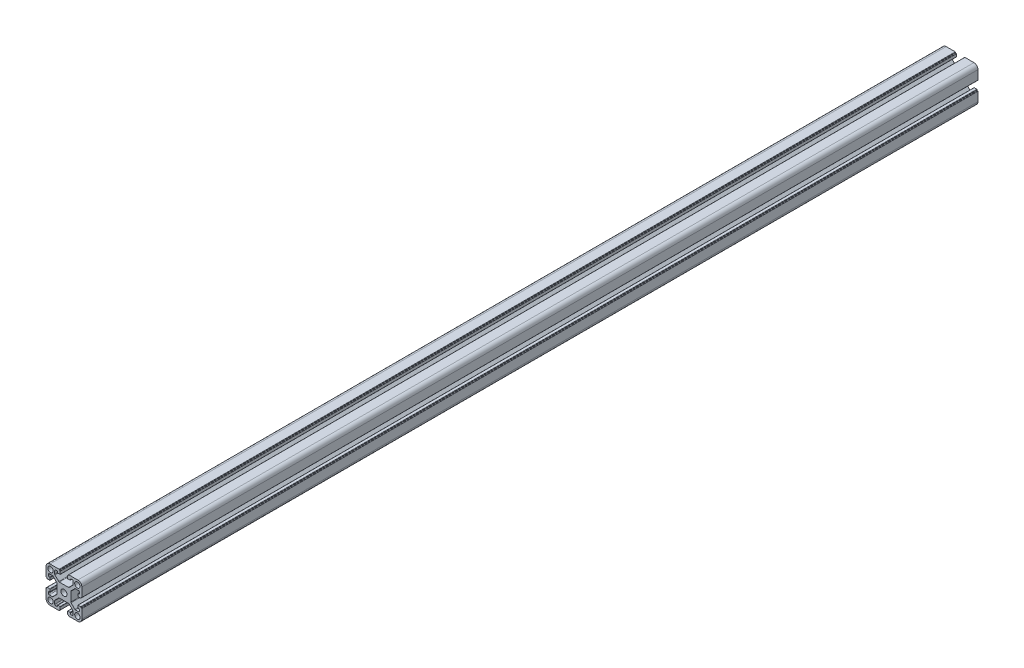
from build123d import *

# Parameters (mm, degrees)
SKETCH_1_R      = 3
SKETCH_1_R_2    = 3.4
EXTRUDE_1_DEPTH = 1000


with BuildPart() as part:
    # Эскиз1 → Бобышка-Вытянуть1 (new body)
    with BuildSketch(Plane.XY):
        with BuildLine():
            Line((-20, 15.5), (-20, 10.25))
            Line((-20, 10.25), (-20, 5.4))
            ThreePointArc((-20, 5.4), (-19.912132034, 5.187867966), (-19.7, 5.1))
            Line((-19.7, 5.1), (-19.3, 5.1))
            ThreePointArc((-19.3, 5.1), (-19.087867966, 5.012132034), (-19, 4.8))
            Line((-19, 4.8), (-19, 4.4))
            ThreePointArc((-19, 4.4), (-18.912132034, 4.187867966), (-18.7, 4.1))
            Line((-18.7, 4.1), (-15.8, 4.1))
            ThreePointArc((-15.8, 4.1), (-15.587867966, 4.187867966), (-15.5, 4.4))
            Line((-15.5, 4.4), (-15.5, 6.8))
            ThreePointArc((-15.5, 6.8), (-15.587867966, 7.012132034), (-15.8, 7.1))
            Line((-15.8, 7.1), (-16.3, 7.1))
            ThreePointArc((-16.3, 7.1), (-17.007106781, 7.392893219), (-17.3, 8.1))
            Line((-17.3, 8.1), (-17.3, 9.25))
            ThreePointArc((-17.3, 9.25), (-17.007106781, 9.957106781), (-16.3, 10.25))
            Line((-16.3, 10.25), (-12.864213562, 10.25))
            ThreePointArc((-12.864213562, 10.25), (-12.48153013, 10.173879533), (-12.157106781, 9.957106781))
            Line((-12.157106781, 9.957106781), (-7.992893219, 5.792893219))
            ThreePointArc((-7.992893219, 5.792893219), (-7.776120467, 5.46846987), (-7.7, 5.085786438))
            Line((-7.7, 5.085786438), (-7.7, -5.085786438))
            ThreePointArc((-7.7, -5.085786438), (-7.776120467, -5.46846987), (-7.992893219, -5.792893219))
            Line((-7.992893219, -5.792893219), (-12.157106781, -9.957106781))
            ThreePointArc((-12.157106781, -9.957106781), (-12.48153013, -10.173879533), (-12.864213562, -10.25))
            Line((-12.864213562, -10.25), (-16.3, -10.25))
            ThreePointArc((-16.3, -10.25), (-17.007106781, -9.957106781), (-17.3, -9.25))
            Line((-17.3, -9.25), (-17.3, -8.1))
            ThreePointArc((-17.3, -8.1), (-17.007106781, -7.392893219), (-16.3, -7.1))
            Line((-16.3, -7.1), (-15.8, -7.1))
            ThreePointArc((-15.8, -7.1), (-15.587867966, -7.012132034), (-15.5, -6.8))
            Line((-15.5, -6.8), (-15.5, -4.4))
            ThreePointArc((-15.5, -4.4), (-15.587867966, -4.187867966), (-15.8, -4.1))
            Line((-15.8, -4.1), (-18.7, -4.1))
            ThreePointArc((-18.7, -4.1), (-18.912132034, -4.187867966), (-19, -4.4))
            Line((-19, -4.4), (-19, -4.8))
            ThreePointArc((-19, -4.8), (-19.087867966, -5.012132034), (-19.3, -5.1))
            Line((-19.3, -5.1), (-19.7, -5.1))
            ThreePointArc((-19.7, -5.1), (-19.912132034, -5.187867966), (-20, -5.4))
            Line((-20, -5.4), (-20, -10.25))
            Line((-20, -10.25), (-20, -15.5))
            ThreePointArc((-20, -15.5), (-18.681980515, -18.681980515), (-15.5, -20))
            Line((-15.5, -20), (-10.25, -20))
            Line((-10.25, -20), (-5.4, -20))
            ThreePointArc((-5.4, -20), (-5.187867966, -19.912132034), (-5.1, -19.7))
            Line((-5.1, -19.7), (-5.1, -19.3))
            ThreePointArc((-5.1, -19.3), (-5.012132034, -19.087867966), (-4.8, -19))
            Line((-4.8, -19), (-4.4, -19))
            ThreePointArc((-4.4, -19), (-4.187867966, -18.912132034), (-4.1, -18.7))
            Line((-4.1, -18.7), (-4.1, -15.8))
            ThreePointArc((-4.1, -15.8), (-4.187867966, -15.587867966), (-4.4, -15.5))
            Line((-4.4, -15.5), (-6.8, -15.5))
            ThreePointArc((-6.8, -15.5), (-7.012132034, -15.587867966), (-7.1, -15.8))
            Line((-7.1, -15.8), (-7.1, -16.3))
            ThreePointArc((-7.1, -16.3), (-7.392893219, -17.007106781), (-8.1, -17.3))
            Line((-8.1, -17.3), (-9.25, -17.3))
            ThreePointArc((-9.25, -17.3), (-9.957106781, -17.007106781), (-10.25, -16.3))
            Line((-10.25, -16.3), (-10.25, -12.864213562))
            ThreePointArc((-10.25, -12.864213562), (-10.173879533, -12.48153013), (-9.957106781, -12.157106781))
            Line((-9.957106781, -12.157106781), (-5.792893219, -7.992893219))
            ThreePointArc((-5.792893219, -7.992893219), (-5.46846987, -7.776120467), (-5.085786438, -7.7))
            Line((-5.085786438, -7.7), (5.085786438, -7.7))
            ThreePointArc((5.085786438, -7.7), (5.46846987, -7.776120467), (5.792893219, -7.992893219))
            Line((5.792893219, -7.992893219), (9.957106781, -12.157106781))
            ThreePointArc((9.957106781, -12.157106781), (10.173879533, -12.48153013), (10.25, -12.864213562))
            Line((10.25, -12.864213562), (10.25, -16.3))
            ThreePointArc((10.25, -16.3), (9.957106781, -17.007106781), (9.25, -17.3))
            Line((9.25, -17.3), (8.1, -17.3))
            ThreePointArc((8.1, -17.3), (7.392893219, -17.007106781), (7.1, -16.3))
            Line((7.1, -16.3), (7.1, -15.8))
            ThreePointArc((7.1, -15.8), (7.012132034, -15.587867966), (6.8, -15.5))
            Line((6.8, -15.5), (4.4, -15.5))
            ThreePointArc((4.4, -15.5), (4.187867966, -15.587867966), (4.1, -15.8))
            Line((4.1, -15.8), (4.1, -18.7))
            ThreePointArc((4.1, -18.7), (4.187867966, -18.912132034), (4.4, -19))
            Line((4.4, -19), (4.8, -19))
            ThreePointArc((4.8, -19), (5.012132034, -19.087867966), (5.1, -19.3))
            Line((5.1, -19.3), (5.1, -19.7))
            ThreePointArc((5.1, -19.7), (5.187867966, -19.912132034), (5.4, -20))
            Line((5.4, -20), (10.25, -20))
            Line((10.25, -20), (15.5, -20))
            ThreePointArc((15.5, -20), (18.681980515, -18.681980515), (20, -15.5))
            Line((20, -15.5), (20, -10.25))
            Line((20, -10.25), (20, -5.4))
            ThreePointArc((20, -5.4), (19.912132034, -5.187867966), (19.7, -5.1))
            Line((19.7, -5.1), (19.3, -5.1))
            ThreePointArc((19.3, -5.1), (19.087867966, -5.012132034), (19, -4.8))
            Line((19, -4.8), (19, -4.4))
            ThreePointArc((19, -4.4), (18.912132034, -4.187867966), (18.7, -4.1))
            Line((18.7, -4.1), (15.8, -4.1))
            ThreePointArc((15.8, -4.1), (15.587867966, -4.187867966), (15.5, -4.4))
            Line((15.5, -4.4), (15.5, -6.8))
            ThreePointArc((15.5, -6.8), (15.587867966, -7.012132034), (15.8, -7.1))
            Line((15.8, -7.1), (16.3, -7.1))
            ThreePointArc((16.3, -7.1), (17.007106781, -7.392893219), (17.3, -8.1))
            Line((17.3, -8.1), (17.3, -9.25))
            ThreePointArc((17.3, -9.25), (17.007106781, -9.957106781), (16.3, -10.25))
            Line((16.3, -10.25), (12.864213562, -10.25))
            ThreePointArc((12.864213562, -10.25), (12.48153013, -10.173879533), (12.157106781, -9.957106781))
            Line((12.157106781, -9.957106781), (7.992893219, -5.792893219))
            ThreePointArc((7.992893219, -5.792893219), (7.776120467, -5.46846987), (7.7, -5.085786438))
            Line((7.7, -5.085786438), (7.7, 5.085786438))
            ThreePointArc((7.7, 5.085786438), (7.776120467, 5.46846987), (7.992893219, 5.792893219))
            Line((7.992893219, 5.792893219), (12.157106781, 9.957106781))
            ThreePointArc((12.157106781, 9.957106781), (12.48153013, 10.173879533), (12.864213562, 10.25))
            Line((12.864213562, 10.25), (16.3, 10.25))
            ThreePointArc((16.3, 10.25), (17.007106781, 9.957106781), (17.3, 9.25))
            Line((17.3, 9.25), (17.3, 8.1))
            ThreePointArc((17.3, 8.1), (17.007106781, 7.392893219), (16.3, 7.1))
            Line((16.3, 7.1), (15.8, 7.1))
            ThreePointArc((15.8, 7.1), (15.587867966, 7.012132034), (15.5, 6.8))
            Line((15.5, 6.8), (15.5, 4.4))
            ThreePointArc((15.5, 4.4), (15.587867966, 4.187867966), (15.8, 4.1))
            Line((15.8, 4.1), (18.7, 4.1))
            ThreePointArc((18.7, 4.1), (18.912132034, 4.187867966), (19, 4.4))
            Line((19, 4.4), (19, 4.8))
            ThreePointArc((19, 4.8), (19.087867966, 5.012132034), (19.3, 5.1))
            Line((19.3, 5.1), (19.7, 5.1))
            ThreePointArc((19.7, 5.1), (19.912132034, 5.187867966), (20, 5.4))
            Line((20, 5.4), (20, 10.25))
            Line((20, 10.25), (20, 15.5))
            ThreePointArc((20, 15.5), (18.681980515, 18.681980515), (15.5, 20))
            Line((15.5, 20), (10.25, 20))
            Line((10.25, 20), (5.4, 20))
            ThreePointArc((5.4, 20), (5.187867966, 19.912132034), (5.1, 19.7))
            Line((5.1, 19.7), (5.1, 19.3))
            ThreePointArc((5.1, 19.3), (5.012132034, 19.087867966), (4.8, 19))
            Line((4.8, 19), (4.4, 19))
            ThreePointArc((4.4, 19), (4.187867966, 18.912132034), (4.1, 18.7))
            Line((4.1, 18.7), (4.1, 15.8))
            ThreePointArc((4.1, 15.8), (4.187867966, 15.587867966), (4.4, 15.5))
            Line((4.4, 15.5), (6.8, 15.5))
            ThreePointArc((6.8, 15.5), (7.012132034, 15.587867966), (7.1, 15.8))
            Line((7.1, 15.8), (7.1, 16.3))
            ThreePointArc((7.1, 16.3), (7.392893219, 17.007106781), (8.1, 17.3))
            Line((8.1, 17.3), (9.25, 17.3))
            ThreePointArc((9.25, 17.3), (9.957106781, 17.007106781), (10.25, 16.3))
            Line((10.25, 16.3), (10.25, 12.864213562))
            ThreePointArc((10.25, 12.864213562), (10.173879533, 12.48153013), (9.957106781, 12.157106781))
            Line((9.957106781, 12.157106781), (5.792893219, 7.992893219))
            ThreePointArc((5.792893219, 7.992893219), (5.46846987, 7.776120467), (5.085786438, 7.7))
            Line((5.085786438, 7.7), (-5.085786438, 7.7))
            ThreePointArc((-5.085786438, 7.7), (-5.46846987, 7.776120467), (-5.792893219, 7.992893219))
            Line((-5.792893219, 7.992893219), (-9.957106781, 12.157106781))
            ThreePointArc((-9.957106781, 12.157106781), (-10.173879533, 12.48153013), (-10.25, 12.864213562))
            Line((-10.25, 12.864213562), (-10.25, 16.3))
            ThreePointArc((-10.25, 16.3), (-9.957106781, 17.007106781), (-9.25, 17.3))
            Line((-9.25, 17.3), (-8.1, 17.3))
            ThreePointArc((-8.1, 17.3), (-7.392893219, 17.007106781), (-7.1, 16.3))
            Line((-7.1, 16.3), (-7.1, 15.8))
            ThreePointArc((-7.1, 15.8), (-7.012132034, 15.587867966), (-6.8, 15.5))
            Line((-6.8, 15.5), (-4.4, 15.5))
            ThreePointArc((-4.4, 15.5), (-4.187867966, 15.587867966), (-4.1, 15.8))
            Line((-4.1, 15.8), (-4.1, 18.7))
            ThreePointArc((-4.1, 18.7), (-4.187867966, 18.912132034), (-4.4, 19))
            Line((-4.4, 19), (-4.8, 19))
            ThreePointArc((-4.8, 19), (-5.012132034, 19.087867966), (-5.1, 19.3))
            Line((-5.1, 19.3), (-5.1, 19.7))
            ThreePointArc((-5.1, 19.7), (-5.187867966, 19.912132034), (-5.4, 20))
            Line((-5.4, 20), (-10.25, 20))
            Line((-10.25, 20), (-15.5, 20))
            ThreePointArc((-15.5, 20), (-18.681980515, 18.681980515), (-20, 15.5))
        make_face()
        with Locations((-15, -15)):
            Circle(SKETCH_1_R, mode=Mode.SUBTRACT)
        with Locations((15, -15)):
            Circle(SKETCH_1_R, mode=Mode.SUBTRACT)
        Circle(SKETCH_1_R_2, mode=Mode.SUBTRACT)
        with Locations((-15, 15)):
            Circle(SKETCH_1_R, mode=Mode.SUBTRACT)
        with Locations((15, 15)):
            Circle(SKETCH_1_R, mode=Mode.SUBTRACT)
    extrude(amount=EXTRUDE_1_DEPTH)


solid = part.part
